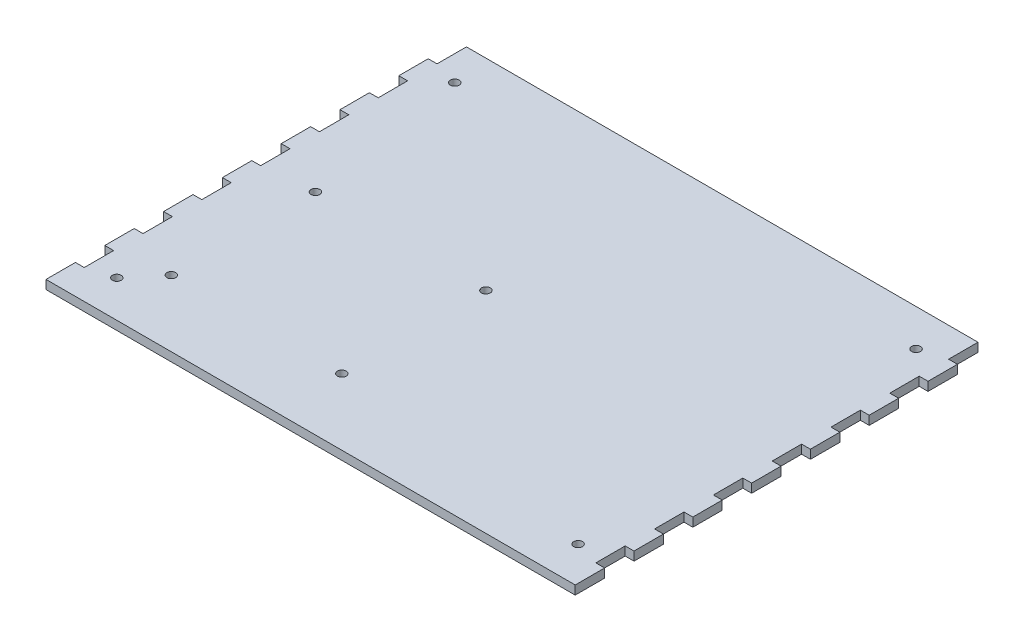
from build123d import *

# Parameters (mm, degrees)
ESQUISSE1_W             = 180
ESQUISSE1_H             = 140
ESQUISSE1_R             = 1.5
BOSS_EXTRU_1_DEPTH      = 3
ENL_V_MAT_EXTRU_1_REACH = 5
ESQUISSE2_W             = 3
ESQUISSE2_H             = 10


with BuildPart() as part:
    # Esquisse1 → Boss.-Extru.1 (new body)
    with BuildSketch(Plane(origin=(0, 0, 0), x_dir=(1, 0, 0), z_dir=(0, 1, 0))):
        Rectangle(ESQUISSE1_W, ESQUISSE1_H)
        with Locations((-78.45, 57.48)):
            Circle(ESQUISSE1_R, mode=Mode.SUBTRACT)
        with Locations((78.45, 57.48)):
            Circle(ESQUISSE1_R, mode=Mode.SUBTRACT)
        with Locations((78.45, -57.48)):
            Circle(ESQUISSE1_R, mode=Mode.SUBTRACT)
        with Locations((-78.45, -57.48)):
            Circle(ESQUISSE1_R, mode=Mode.SUBTRACT)
        with Locations((-69.95, 1.57626837)):
            Circle(ESQUISSE1_R, mode=Mode.SUBTRACT)
        with Locations((-11.95, 1.57626837)):
            Circle(ESQUISSE1_R, mode=Mode.SUBTRACT)
        with Locations((-69.95, -47.42373163)):
            Circle(ESQUISSE1_R, mode=Mode.SUBTRACT)
        with Locations((-11.95, -47.42373163)):
            Circle(ESQUISSE1_R, mode=Mode.SUBTRACT)
    extrude(amount=BOSS_EXTRU_1_DEPTH)

    # Esquisse2 → Enlèv. mat.-Extru.1 (cut, up to next)
    with BuildSketch(Plane(origin=(0, 3, 0), x_dir=(1, 0, 0), z_dir=(0, 1, 0)), mode=Mode.PRIVATE) as enl_v_mat_extru_1_sk1:
        with Locations((-88.5, 45)):
            Rectangle(ESQUISSE2_W, ESQUISSE2_H)
    enl_v_mat_extru_1_tool1 = extrude(enl_v_mat_extru_1_sk1.sketch, amount=-ENL_V_MAT_EXTRU_1_REACH, mode=Mode.PRIVATE) & part.part
    add(enl_v_mat_extru_1_tool1.solids().sort_by_distance((-88.5, 3, -45))[0], mode=Mode.SUBTRACT)
    # Esquisse2 → Enlèv. mat.-Extru.1 (cut, up to next)
    with BuildSketch(Plane(origin=(0, 3, 0), x_dir=(1, 0, 0), z_dir=(0, 1, 0)), mode=Mode.PRIVATE) as enl_v_mat_extru_1_sk2:
        with Locations((-88.5, 65)):
            Rectangle(ESQUISSE2_W, ESQUISSE2_H)
    enl_v_mat_extru_1_tool2 = extrude(enl_v_mat_extru_1_sk2.sketch, amount=-ENL_V_MAT_EXTRU_1_REACH, mode=Mode.PRIVATE) & part.part
    add(enl_v_mat_extru_1_tool2.solids().sort_by_distance((-88.5, 3, -65))[0], mode=Mode.SUBTRACT)
    # Esquisse2 → Enlèv. mat.-Extru.1 (cut, up to next)
    with BuildSketch(Plane(origin=(0, 3, 0), x_dir=(1, 0, 0), z_dir=(0, 1, 0)), mode=Mode.PRIVATE) as enl_v_mat_extru_1_sk3:
        with Locations((-88.5, 25)):
            Rectangle(ESQUISSE2_W, ESQUISSE2_H)
    enl_v_mat_extru_1_tool3 = extrude(enl_v_mat_extru_1_sk3.sketch, amount=-ENL_V_MAT_EXTRU_1_REACH, mode=Mode.PRIVATE) & part.part
    add(enl_v_mat_extru_1_tool3.solids().sort_by_distance((-88.5, 3, -25))[0], mode=Mode.SUBTRACT)
    # Esquisse2 → Enlèv. mat.-Extru.1 (cut, up to next)
    with BuildSketch(Plane(origin=(0, 3, 0), x_dir=(1, 0, 0), z_dir=(0, 1, 0)), mode=Mode.PRIVATE) as enl_v_mat_extru_1_sk4:
        with Locations((-88.5, 5)):
            Rectangle(ESQUISSE2_W, ESQUISSE2_H)
    enl_v_mat_extru_1_tool4 = extrude(enl_v_mat_extru_1_sk4.sketch, amount=-ENL_V_MAT_EXTRU_1_REACH, mode=Mode.PRIVATE) & part.part
    add(enl_v_mat_extru_1_tool4.solids().sort_by_distance((-88.5, 3, -5))[0], mode=Mode.SUBTRACT)
    # Esquisse2 → Enlèv. mat.-Extru.1 (cut, up to next)
    with BuildSketch(Plane(origin=(0, 3, 0), x_dir=(1, 0, 0), z_dir=(0, 1, 0)), mode=Mode.PRIVATE) as enl_v_mat_extru_1_sk5:
        with Locations((-88.5, -15)):
            Rectangle(ESQUISSE2_W, ESQUISSE2_H)
    enl_v_mat_extru_1_tool5 = extrude(enl_v_mat_extru_1_sk5.sketch, amount=-ENL_V_MAT_EXTRU_1_REACH, mode=Mode.PRIVATE) & part.part
    add(enl_v_mat_extru_1_tool5.solids().sort_by_distance((-88.5, 3, 15))[0], mode=Mode.SUBTRACT)
    # Esquisse2 → Enlèv. mat.-Extru.1 (cut, up to next)
    with BuildSketch(Plane(origin=(0, 3, 0), x_dir=(1, 0, 0), z_dir=(0, 1, 0)), mode=Mode.PRIVATE) as enl_v_mat_extru_1_sk6:
        with Locations((-88.5, -35)):
            Rectangle(ESQUISSE2_W, ESQUISSE2_H)
    enl_v_mat_extru_1_tool6 = extrude(enl_v_mat_extru_1_sk6.sketch, amount=-ENL_V_MAT_EXTRU_1_REACH, mode=Mode.PRIVATE) & part.part
    add(enl_v_mat_extru_1_tool6.solids().sort_by_distance((-88.5, 3, 35))[0], mode=Mode.SUBTRACT)
    # Esquisse2 → Enlèv. mat.-Extru.1 (cut, up to next)
    with BuildSketch(Plane(origin=(0, 3, 0), x_dir=(1, 0, 0), z_dir=(0, 1, 0)), mode=Mode.PRIVATE) as enl_v_mat_extru_1_sk7:
        with Locations((-88.5, -55)):
            Rectangle(ESQUISSE2_W, ESQUISSE2_H)
    enl_v_mat_extru_1_tool7 = extrude(enl_v_mat_extru_1_sk7.sketch, amount=-ENL_V_MAT_EXTRU_1_REACH, mode=Mode.PRIVATE) & part.part
    add(enl_v_mat_extru_1_tool7.solids().sort_by_distance((-88.5, 3, 55))[0], mode=Mode.SUBTRACT)
    # Esquisse2 → Enlèv. mat.-Extru.1 (cut, up to next)
    with BuildSketch(Plane(origin=(0, 3, 0), x_dir=(1, 0, 0), z_dir=(0, 1, 0)), mode=Mode.PRIVATE) as enl_v_mat_extru_1_sk8:
        with Locations((88.5, -55)):
            Rectangle(ESQUISSE2_W, ESQUISSE2_H)
    enl_v_mat_extru_1_tool8 = extrude(enl_v_mat_extru_1_sk8.sketch, amount=-ENL_V_MAT_EXTRU_1_REACH, mode=Mode.PRIVATE) & part.part
    add(enl_v_mat_extru_1_tool8.solids().sort_by_distance((88.5, 3, 55))[0], mode=Mode.SUBTRACT)
    # Esquisse2 → Enlèv. mat.-Extru.1 (cut, up to next)
    with BuildSketch(Plane(origin=(0, 3, 0), x_dir=(1, 0, 0), z_dir=(0, 1, 0)), mode=Mode.PRIVATE) as enl_v_mat_extru_1_sk9:
        with Locations((88.5, -35)):
            Rectangle(ESQUISSE2_W, ESQUISSE2_H)
    enl_v_mat_extru_1_tool9 = extrude(enl_v_mat_extru_1_sk9.sketch, amount=-ENL_V_MAT_EXTRU_1_REACH, mode=Mode.PRIVATE) & part.part
    add(enl_v_mat_extru_1_tool9.solids().sort_by_distance((88.5, 3, 35))[0], mode=Mode.SUBTRACT)
    # Esquisse2 → Enlèv. mat.-Extru.1 (cut, up to next)
    with BuildSketch(Plane(origin=(0, 3, 0), x_dir=(1, 0, 0), z_dir=(0, 1, 0)), mode=Mode.PRIVATE) as enl_v_mat_extru_1_sk10:
        with Locations((88.5, -15)):
            Rectangle(ESQUISSE2_W, ESQUISSE2_H)
    enl_v_mat_extru_1_tool10 = extrude(enl_v_mat_extru_1_sk10.sketch, amount=-ENL_V_MAT_EXTRU_1_REACH, mode=Mode.PRIVATE) & part.part
    add(enl_v_mat_extru_1_tool10.solids().sort_by_distance((88.5, 3, 15))[0], mode=Mode.SUBTRACT)
    # Esquisse2 → Enlèv. mat.-Extru.1 (cut, up to next)
    with BuildSketch(Plane(origin=(0, 3, 0), x_dir=(1, 0, 0), z_dir=(0, 1, 0)), mode=Mode.PRIVATE) as enl_v_mat_extru_1_sk11:
        with Locations((88.5, 5)):
            Rectangle(ESQUISSE2_W, ESQUISSE2_H)
    enl_v_mat_extru_1_tool11 = extrude(enl_v_mat_extru_1_sk11.sketch, amount=-ENL_V_MAT_EXTRU_1_REACH, mode=Mode.PRIVATE) & part.part
    add(enl_v_mat_extru_1_tool11.solids().sort_by_distance((88.5, 3, -5))[0], mode=Mode.SUBTRACT)
    # Esquisse2 → Enlèv. mat.-Extru.1 (cut, up to next)
    with BuildSketch(Plane(origin=(0, 3, 0), x_dir=(1, 0, 0), z_dir=(0, 1, 0)), mode=Mode.PRIVATE) as enl_v_mat_extru_1_sk12:
        with Locations((88.5, 25)):
            Rectangle(ESQUISSE2_W, ESQUISSE2_H)
    enl_v_mat_extru_1_tool12 = extrude(enl_v_mat_extru_1_sk12.sketch, amount=-ENL_V_MAT_EXTRU_1_REACH, mode=Mode.PRIVATE) & part.part
    add(enl_v_mat_extru_1_tool12.solids().sort_by_distance((88.5, 3, -25))[0], mode=Mode.SUBTRACT)
    # Esquisse2 → Enlèv. mat.-Extru.1 (cut, up to next)
    with BuildSketch(Plane(origin=(0, 3, 0), x_dir=(1, 0, 0), z_dir=(0, 1, 0)), mode=Mode.PRIVATE) as enl_v_mat_extru_1_sk13:
        with Locations((88.5, 45)):
            Rectangle(ESQUISSE2_W, ESQUISSE2_H)
    enl_v_mat_extru_1_tool13 = extrude(enl_v_mat_extru_1_sk13.sketch, amount=-ENL_V_MAT_EXTRU_1_REACH, mode=Mode.PRIVATE) & part.part
    add(enl_v_mat_extru_1_tool13.solids().sort_by_distance((88.5, 3, -45))[0], mode=Mode.SUBTRACT)
    # Esquisse2 → Enlèv. mat.-Extru.1 (cut, up to next)
    with BuildSketch(Plane(origin=(0, 3, 0), x_dir=(1, 0, 0), z_dir=(0, 1, 0)), mode=Mode.PRIVATE) as enl_v_mat_extru_1_sk14:
        with Locations((88.5, 65)):
            Rectangle(ESQUISSE2_W, ESQUISSE2_H)
    enl_v_mat_extru_1_tool14 = extrude(enl_v_mat_extru_1_sk14.sketch, amount=-ENL_V_MAT_EXTRU_1_REACH, mode=Mode.PRIVATE) & part.part
    add(enl_v_mat_extru_1_tool14.solids().sort_by_distance((88.5, 3, -65))[0], mode=Mode.SUBTRACT)


solid = part.part
